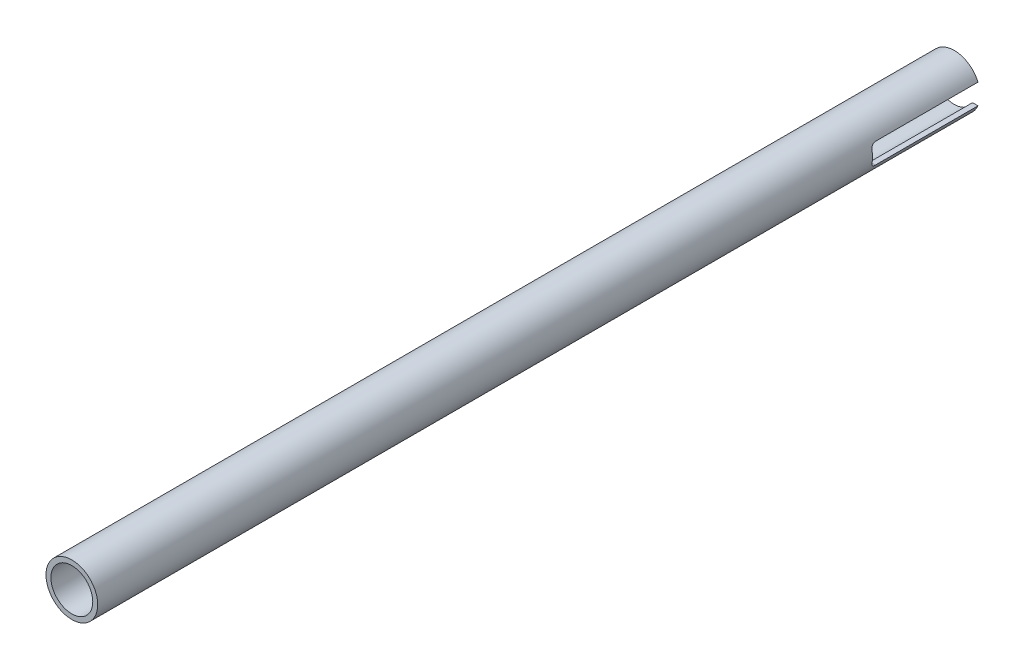
from build123d import *

# Parameters (mm, degrees)
SKETCH1_R               = 8.001
SKETCH1_R_2             = 6.477
BOSS_EXTRUDE1_DEPTH     = 273.05
CUT_EXTRUDE1_DEPTH      = 9.001
CUT_EXTRUDE1_DEPTH_BACK = 9.001


with BuildPart() as part:
    # Sketch1 → Boss-Extrude1 (new body)
    with BuildSketch(Plane.XY):
        Circle(SKETCH1_R)
        Circle(SKETCH1_R_2, mode=Mode.SUBTRACT)
    extrude(amount=BOSS_EXTRUDE1_DEPTH)

    # Sketch2 → Cut-Extrude1 (cut, two sides)
    with BuildSketch(Plane(origin=(0, 0, 0), x_dir=(0, 0, -1), z_dir=(1, 0, 0))) as cut_extrude1_sk:
        with BuildLine():
            Line((556.557244855, 3.175), (0, 3.175))
            Line((0, 3.175), (-31.75, 3.175))
            ThreePointArc((-31.75, 3.175), (-32.827630735, 2.728630735), (-33.274, 1.651))
            Line((-33.274, 1.651), (-33.274, -1.651))
            ThreePointArc((-33.274, -1.651), (-32.827630735, -2.728630735), (-31.75, -3.175))
            Line((-31.75, -3.175), (0, -3.175))
            Line((0, -3.175), (556.557244855, -3.175))
            Line((556.557244855, -3.175), (1669.671734566, -3.175))
            Line((1669.671734566, -3.175), (1669.671734566, 3.175))
            Line((1669.671734566, 3.175), (556.557244855, 3.175))
        make_face()
    extrude(amount=CUT_EXTRUDE1_DEPTH, mode=Mode.SUBTRACT)
    extrude(cut_extrude1_sk.sketch, amount=-CUT_EXTRUDE1_DEPTH_BACK, mode=Mode.SUBTRACT)


solid = part.part
